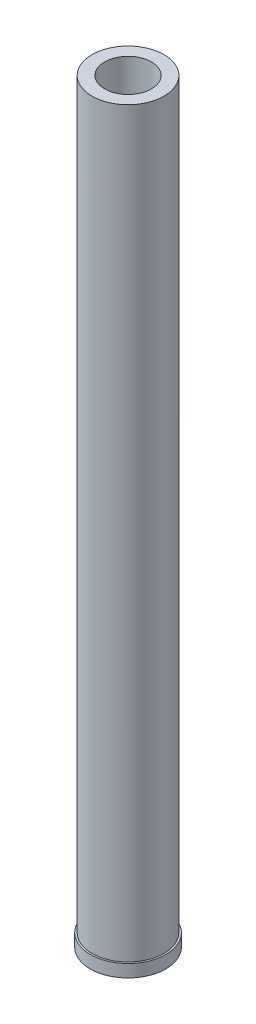
from build123d import *

# Parameters (mm, degrees)
SKETCH1_R           = 14.3
SKETCH1_R_2         = 9.3
BOSS_EXTRUDE1_DEPTH = 300
SKETCH2_W           = 0.7
SKETCH2_H           = 5


with BuildPart() as part:
    # Sketch1 → Boss-Extrude1 (new body)
    with BuildSketch(Plane(origin=(0, 0, 0), x_dir=(1, 0, 0), z_dir=(0, 1, 0))):
        Circle(SKETCH1_R)
        Circle(SKETCH1_R_2, mode=Mode.SUBTRACT)
    extrude(amount=BOSS_EXTRUDE1_DEPTH)

    # Sketch2 → Revolve1 (revolve)
    with BuildSketch(Plane.XY):
        with Locations((-14.65, 2.5)):
            Rectangle(SKETCH2_W, SKETCH2_H)
    revolve(axis=Axis((0, 0, 0), (0, 1, 0)))


solid = part.part
